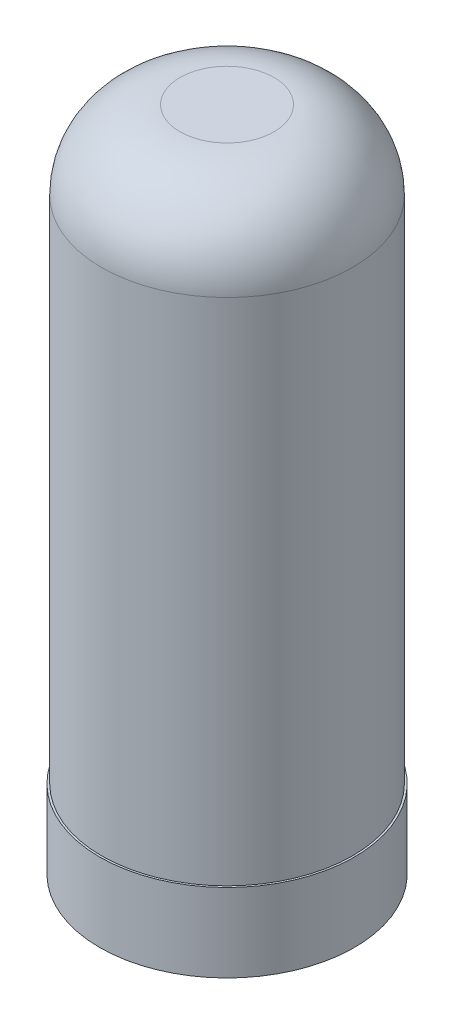
from build123d import *

# Parameters (mm, degrees)
ESQUISSE1_R        = 32.5
ESQUISSE1_R_2      = 3.25
BOSS_EXTRU_1_DEPTH = 20
ESQUISSE2_R        = 32
BOSS_EXTRU_2_DEPTH = 150
CONG_1_R           = 20


with BuildPart() as part:
    # Esquisse1 → Boss.-Extru.1 (new body)
    with BuildSketch(Plane(origin=(0, 0, 0), x_dir=(1, 0, 0), z_dir=(0, 1, 0))):
        Circle(ESQUISSE1_R)
        Circle(ESQUISSE1_R_2, mode=Mode.SUBTRACT)
    extrude(amount=BOSS_EXTRU_1_DEPTH)

    # Esquisse2 → Boss.-Extru.2 (add)
    with BuildSketch(Plane(origin=(0, 20, 0), x_dir=(1, 0, 0), z_dir=(0, 1, 0))):
        Circle(ESQUISSE2_R)
    extrude(amount=BOSS_EXTRU_2_DEPTH)

    # Congé1
    cong_1_edges = [part.edges().sort_by_distance(p)[0] for p in [
        (-32, 170, 0),
    ]]
    fillet(cong_1_edges, radius=CONG_1_R)


solid = part.part
